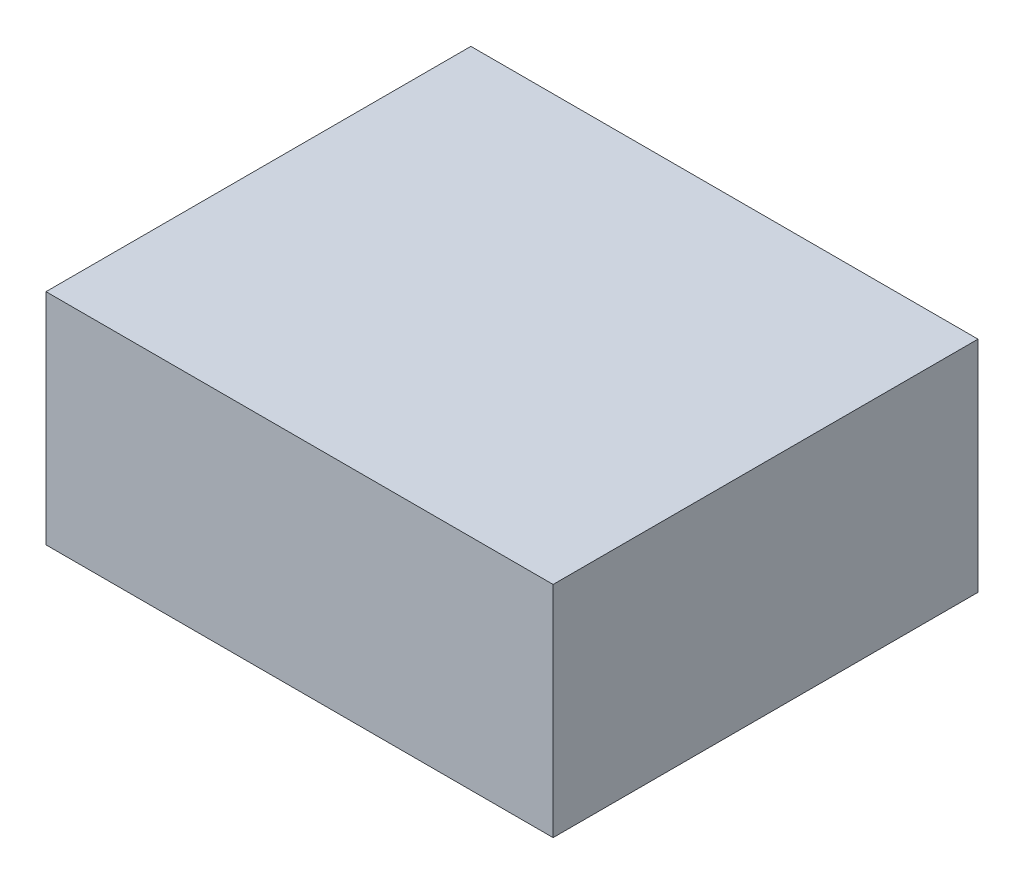
from build123d import *

# Parameters (mm, degrees)
USBPORT_SKETCH_W      = 9.25
USBPORT_SKETCH_H      = 7.75
USBPORT_EXTRUDE_DEPTH = 4


with BuildPart() as part:
    # USBPort Sketch → USBPort Extrude (new body)
    with BuildSketch(Plane(origin=(0, 0, 0), x_dir=(1, 0, 0), z_dir=(0, 1, 0))):
        with Locations((4.625, 3.875)):
            Rectangle(USBPORT_SKETCH_W, USBPORT_SKETCH_H)
    extrude(amount=USBPORT_EXTRUDE_DEPTH)


solid = part.part
